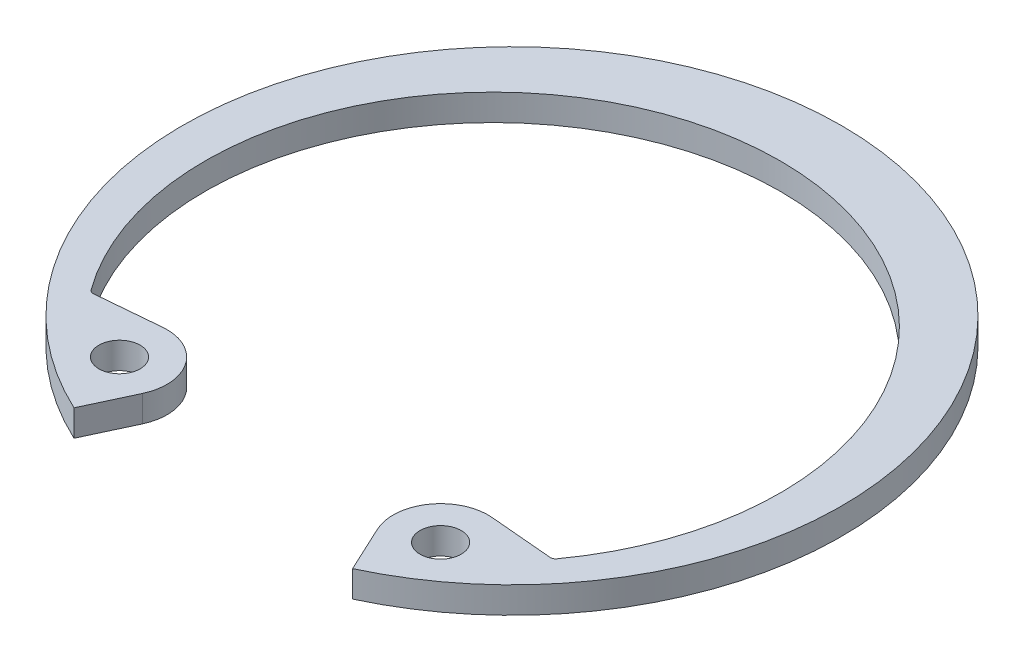
from build123d import *

# Parameters (mm, degrees)
SKETCH2_R      = 0.9906
EXTRUDE1_DEPTH = 1.27
FILLET1_R      = 0.254


with BuildPart() as part:
    # Sketch2 → Extrude1 (new body)
    with BuildSketch(Plane(origin=(0, 0, 0), x_dir=(1, 0, 0), z_dir=(0, 1, 0))):
        with BuildLine():
            Line((6.703697653, -14.37612601), (5.655670247, -12.128623984))
            ThreePointArc((5.655670247, -12.128623984), (5.854908275, -9.851322904), (7.926727876, -8.885217558))
            Line((7.926727876, -8.885217558), (11.125604013, -9.165082956))
            ThreePointArc((11.125604013, -9.165082956), (0, 12.9159), (-11.125604013, -9.165082956))
            Line((-11.125604013, -9.165082956), (-7.926727876, -8.885217558))
            ThreePointArc((-7.926727876, -8.885217558), (-5.854908275, -9.851322904), (-5.655670247, -12.128623984))
            Line((-5.655670247, -12.128623984), (-6.703697653, -14.37612601))
            ThreePointArc((-6.703697653, -14.37612601), (0, 15.8623), (6.703697653, -14.37612601))
        make_face()
        with Locations((7.727489848, -11.162518638)):
            Circle(SKETCH2_R, mode=Mode.SUBTRACT)
        with Locations((-7.727489848, -11.162518638)):
            Circle(SKETCH2_R, mode=Mode.SUBTRACT)
    extrude(amount=-EXTRUDE1_DEPTH)

    # Fillet1
    fillet1_edges = [part.edges().sort_by_distance(p)[0] for p in [
        (-11.125604013, -0.635, 9.165082956),
        (11.125604013, -0.635, 9.165082956),
    ]]
    fillet(fillet1_edges, radius=FILLET1_R)


solid = part.part
